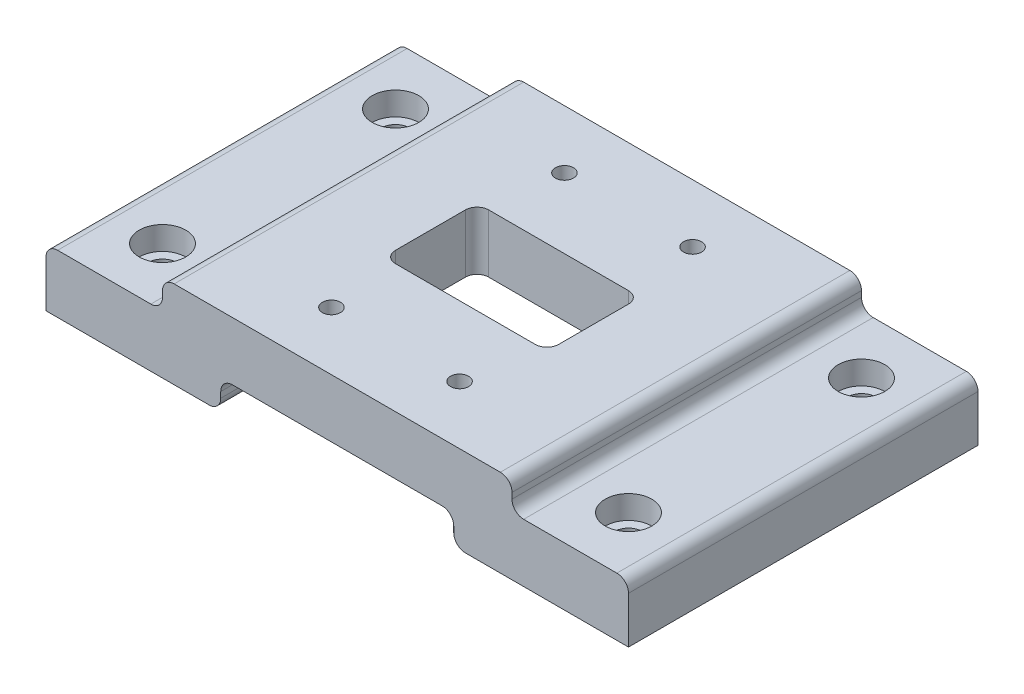
from build123d import *

# Parameters (mm, degrees)
SKETCH2_W                        = 60
SKETCH2_H                        = 60
BOSS_EXTRUDE1_DEPTH              = 10
SKETCH7_W                        = 28
SKETCH7_H                        = 16
CUT_EXTRUDE2_DEPTH               = 44.588989435
FILLET2_R                        = 2
CBORE_FOR_M2_5_SHCS2_D           = 3.1
CBORE_FOR_M2_5_SHCS2_CBORE_D     = 5.5
CBORE_FOR_M2_5_SHCS2_CBORE_DEPTH = 2.5
MOVE_FACE1_BY                    = 3.5
MOVE_FACE1_2_BY                  = 3.5
MOVE_FACE1_3_BY                  = 3.5
MOVE_FACE1_4_BY                  = 3.5
SKETCH11_W                       = 10
SKETCH11_H                       = 5
BOSS_EXTRUDE2_DEPTH              = 60
SKETCH12_W                       = 20
SKETCH12_H                       = 60
BOSS_EXTRUDE3_DEPTH              = 10
CBORE_FOR_M4_SHCS1_D             = 4.8
CBORE_FOR_M4_SHCS1_CBORE_D       = 8
CBORE_FOR_M4_SHCS1_CBORE_DEPTH   = 4
FILLET5_R                        = 2


with BuildPart() as part:
    # Sketch2 → Boss-Extrude1 (new body)
    with BuildSketch(Plane(origin=(0, 0, 0), x_dir=(1, 0, 0), z_dir=(0, 1, 0))):
        Rectangle(SKETCH2_W, SKETCH2_H)
    extrude(amount=BOSS_EXTRUDE1_DEPTH)

    # Sketch7 → Cut-Extrude2 (cut, through all)
    with BuildSketch(Plane(origin=(0, 10, 0), x_dir=(1, 0, 0), z_dir=(0, 1, 0))):
        Rectangle(SKETCH7_W, SKETCH7_H)
    extrude(amount=-CUT_EXTRUDE2_DEPTH, mode=Mode.SUBTRACT)

    # Fillet2
    fillet2_edges = [part.edges().sort_by_distance(p)[0] for p in [
        (-14, 5, 8),
        (-14, 5, -8),
        (14, 5, -8),
        (14, 5, 8),
    ]]
    fillet(fillet2_edges, radius=FILLET2_R)

    # CBORE for M2.5 SHCS2 (through all)
    with Locations(Plane(origin=(0, 0, 0), x_dir=(-1, 0, 0), z_dir=(0, -1, 0))):
        with Locations((11, -20), (-11, -20), (11, 20), (-11, 20)):
            CounterBoreHole(CBORE_FOR_M2_5_SHCS2_D / 2, CBORE_FOR_M2_5_SHCS2_CBORE_D / 2, CBORE_FOR_M2_5_SHCS2_CBORE_DEPTH)

    # Move Face1: a face moved inward by 3.5
    extrude(part.faces().sort_by_distance((11, 2.5, 22.2))[0], amount=MOVE_FACE1_BY, dir=(0, 1, 0), mode=Mode.SUBTRACT)

    # Move Face1 2: a face moved inward by 3.5
    extrude(part.faces().sort_by_distance((-11, 2.5, 22.2))[0], amount=MOVE_FACE1_2_BY, dir=(0, 1, 0), mode=Mode.SUBTRACT)

    # Move Face1 3: a face moved inward by 3.5
    extrude(part.faces().sort_by_distance((11, 2.5, -17.8))[0], amount=MOVE_FACE1_3_BY, dir=(0, 1, 0), mode=Mode.SUBTRACT)

    # Move Face1 4: a face moved inward by 3.5
    extrude(part.faces().sort_by_distance((-11, 2.5, -17.8))[0], amount=MOVE_FACE1_4_BY, dir=(0, 1, 0), mode=Mode.SUBTRACT)

    # Sketch11 → Boss-Extrude2 (add)
    with BuildSketch(Plane(origin=(0, 0, -30), x_dir=(-1, 0, 0), z_dir=(0, 0, -1))):
        with Locations((-25, -2.5)):
            Rectangle(SKETCH11_W, SKETCH11_H)
    boss_extrude2 = extrude(amount=-BOSS_EXTRUDE2_DEPTH)

    # Sketch12 → Boss-Extrude3 (add)
    with BuildSketch(Plane.XZ.offset(5)):
        with Locations((40, 0)):
            Rectangle(SKETCH12_W, SKETCH12_H)
    boss_extrude3 = extrude(amount=-BOSS_EXTRUDE3_DEPTH)

    # CBORE for M4 SHCS1 (through all)
    with Locations(Plane(origin=(0, 5, 0), x_dir=(1, 0, 0), z_dir=(0, 1, 0))):
        with Locations((40, 20), (40, -20)):
            cbore_for_m4_shcs1 = CounterBoreHole(CBORE_FOR_M4_SHCS1_D / 2, CBORE_FOR_M4_SHCS1_CBORE_D / 2, CBORE_FOR_M4_SHCS1_CBORE_DEPTH)

    # Mirror1: Boss-Extrude2, Boss-Extrude3, CBORE for M4 SHCS1 across plane
    add(boss_extrude2.mirror(Plane(origin=(0, 0, 0), x_dir=(0, 0, 1), z_dir=(1, 0, 0))))
    add(boss_extrude3.mirror(Plane(origin=(0, 0, 0), x_dir=(0, 0, 1), z_dir=(1, 0, 0))))
    add(cbore_for_m4_shcs1.mirror(Plane(origin=(0, 0, 0), x_dir=(0, 0, 1), z_dir=(1, 0, 0))), mode=Mode.SUBTRACT)

    # Fillet5
    fillet5_edges = [part.edges().sort_by_distance(p)[0] for p in [
        (50, 5, 0),
        (30, 5, 0),
        (30, 10, 0),
        (-20, 0, 0),
        (-20, -5, 0),
        (-30, 5, 0),
        (-50, 5, 0),
        (-30, 10, 0),
        (20, 0, 0),
        (20, -5, 0),
    ]]
    fillet(fillet5_edges, radius=FILLET5_R)


solid = part.part
